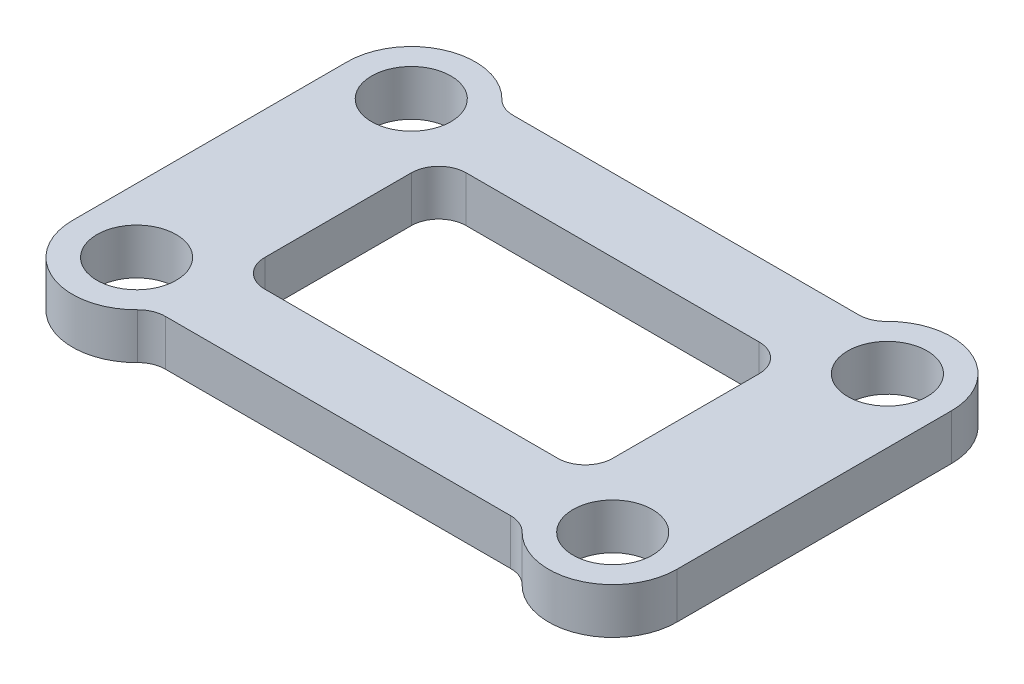
from build123d import *

# Parameters (mm, degrees)
BOSS_EXTRUDE2_DEPTH   = 3.175
BOSS_EXTRUDE2_2_DEPTH = 3.175
SKETCH7_W             = 33.02
SKETCH7_H             = 5.08
EXTRUDE_THIN1_DEPTH   = 3.175
M5_CLEARANCE_HOLE1_D  = 5.5
FILLET1_R             = 1.905


with BuildPart() as part:
    # Sketch1 → Boss-Extrude2 (new body)
    with BuildSketch(Plane.XZ.offset(19.05)):
        with BuildLine():
            Line((-24.765, 9.525), (-24.765, -9.525))
            ThreePointArc((-24.765, -9.525), (-29.21, -13.97), (-33.655, -9.525))
            Line((-33.655, -9.525), (-33.655, 9.525))
            ThreePointArc((-33.655, 9.525), (-29.21, 13.97), (-24.765, 9.525))
        make_face()
    extrude(amount=BOSS_EXTRUDE2_DEPTH)



with BuildPart() as body_2:
    # Sketch1 → Boss-Extrude2 2 (new body)
    with BuildSketch(Plane.XZ.offset(19.05)):
        with BuildLine():
            Line((8.255, 9.525), (8.255, -9.525))
            ThreePointArc((8.255, -9.525), (3.81, -13.97), (-0.635, -9.525))
            Line((-0.635, -9.525), (-0.635, 9.525))
            ThreePointArc((-0.635, 9.525), (3.81, 13.97), (8.255, 9.525))
        make_face()
    extrude(amount=BOSS_EXTRUDE2_2_DEPTH)


with BuildPart() as part_1:
    add(part.part)

    add(body_2.part)  # Extrude-Thin1 merges body 2
    # Sketch7 → Extrude-Thin1 (add)
    with BuildSketch(Plane.XZ.offset(22.225)):
        with Locations((-12.7, 9.525)):
            Rectangle(SKETCH7_W, SKETCH7_H)
        with Locations((-12.7, -9.525)):
            Rectangle(SKETCH7_W, SKETCH7_H)
    extrude(amount=-EXTRUDE_THIN1_DEPTH)

    # M5 Clearance Hole1 (through all)
    with Locations(Plane(origin=(-29.21, -22.225, 9.525), x_dir=(0, 0, -1), z_dir=(0, -1, 0))):
        with Locations((0, 0), (19.05, 0), (0, 33.02), (19.05, 33.02)):
            Hole(M5_CLEARANCE_HOLE1_D / 2)

    # Fillet1
    fillet1_edges = [part_1.edges().sort_by_distance(p)[0] for p in [
        (-25.562202719, -20.6375, 12.065),
        (-24.765, -20.6375, 6.985),
        (-0.635, -20.6375, 6.985),
        (0.162202719, -20.6375, 12.065),
        (0.162202719, -20.6375, -12.065),
        (-0.635, -20.6375, -6.985),
        (-24.765, -20.6375, -6.985),
        (-25.562202719, -20.6375, -12.065),
    ]]
    fillet(fillet1_edges, radius=FILLET1_R)


solid = part_1.part
